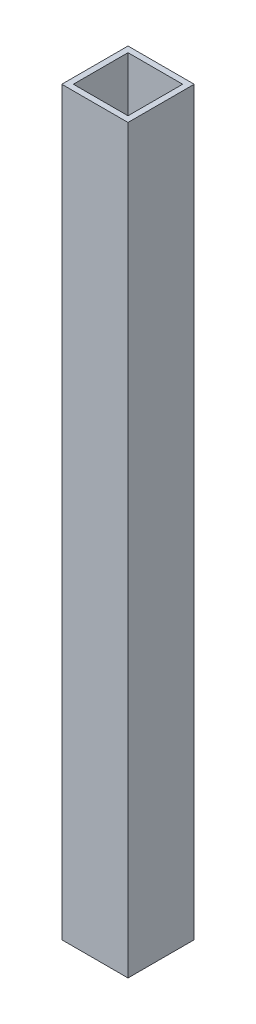
from build123d import *

# Parameters (mm, degrees)
SKETCH1_W           = 18.9
SKETCH1_H           = 18.9
SKETCH1_W_2         = 15.6
SKETCH1_H_2         = 15.6
BOSS_EXTRUDE1_DEPTH = 211.5


with BuildPart() as part:
    # Sketch1 → Boss-Extrude1 (new body)
    with BuildSketch(Plane(origin=(0, 0, 0), x_dir=(1, 0, 0), z_dir=(0, 1, 0))):
        Rectangle(SKETCH1_W, SKETCH1_H)
        Rectangle(SKETCH1_W_2, SKETCH1_H_2, mode=Mode.SUBTRACT)
    extrude(amount=BOSS_EXTRUDE1_DEPTH)


solid = part.part
